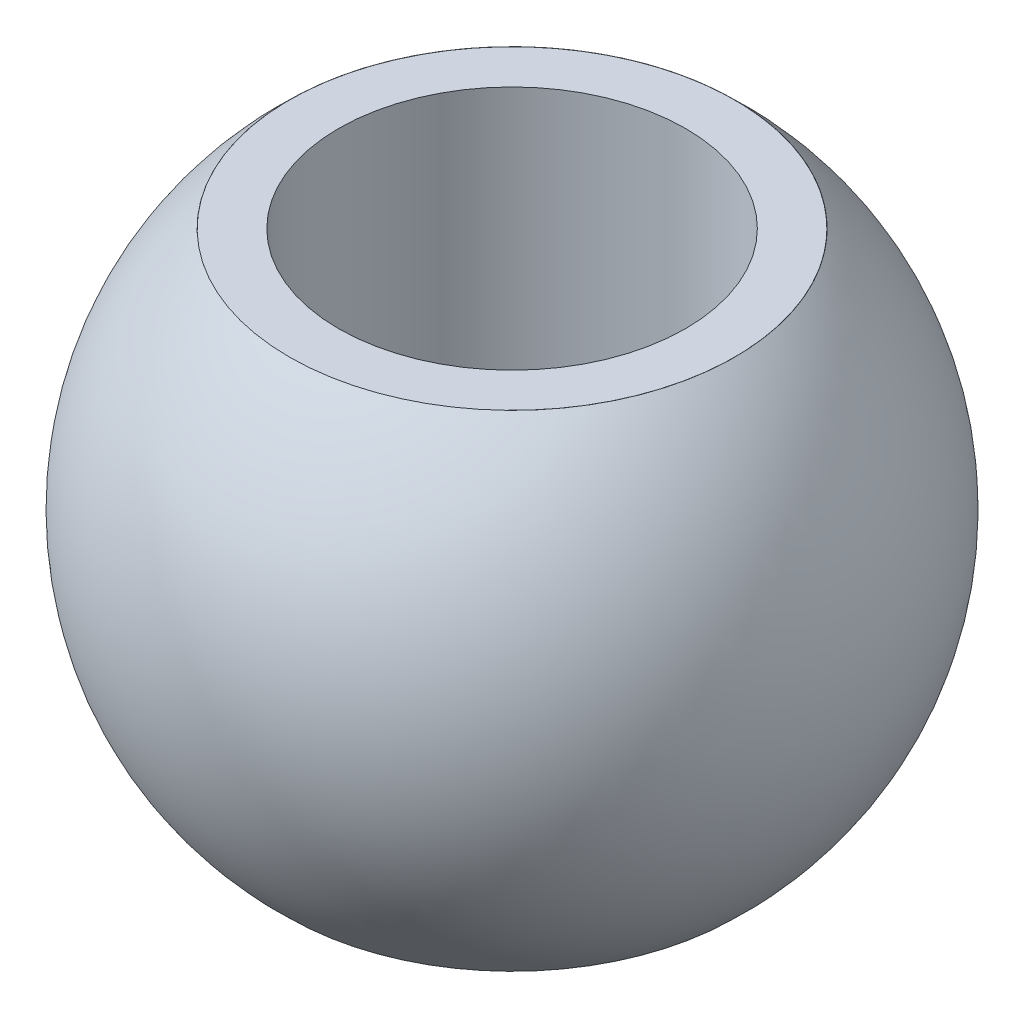
from build123d import *

# Parameters (mm, degrees)
CUT_EXTRUDE1_DEPTH      = 17.454482672
CUT_EXTRUDE1_DEPTH_BACK = 17.454482672
SKETCH1_3_R             = 5
CUT_EXTRUDE2_START      = 7
SKETCH1_4_R             = 6.42
SKETCH1_4_R_2           = 5
CUT_EXTRUDE2_DEPTH      = 10.454482672
CUT_EXTRUDE3_START      = -7
SKETCH1_5_R             = 6.42
SKETCH1_5_R_2           = 5
CUT_EXTRUDE3_DEPTH      = 10.454482672


with BuildPart() as part:
    # Sketch1 → Revolve1 (revolve)
    with BuildSketch(Plane(origin=(0, 0, 0), x_dir=(1, 0, 0), z_dir=(0, 1, 0))):
        with BuildLine():
            ThreePointArc((9.5, 0), (0, 9.5), (-9.5, 0))
            Line((-9.5, 0), (9.5, 0))
        make_face()
    revolve(axis=Axis((-9.5, 0, 0), (1, 0, 0)))

    # Sketch1_3 → Cut-Extrude1 (cut, two sides: drawn at the far end of the back side and taken through both)
    with BuildSketch(Plane(origin=(0, 0, 0), x_dir=(1, 0, 0), z_dir=(0, 1, 0)).offset(-CUT_EXTRUDE1_DEPTH_BACK)):
        Circle(SKETCH1_3_R)
    extrude(amount=CUT_EXTRUDE1_DEPTH + CUT_EXTRUDE1_DEPTH_BACK, mode=Mode.SUBTRACT)

    # Sketch1_4 → Cut-Extrude2 (cut, through all)
    with BuildSketch(Plane(origin=(0, 0, 0), x_dir=(1, 0, 0), z_dir=(0, 1, 0)).offset(CUT_EXTRUDE2_START)):
        Circle(SKETCH1_4_R)
        Circle(SKETCH1_4_R_2, mode=Mode.SUBTRACT)
    extrude(amount=CUT_EXTRUDE2_DEPTH, mode=Mode.SUBTRACT)

    # Sketch1_5 → Cut-Extrude3 (cut, through all)
    with BuildSketch(Plane(origin=(0, 0, 0), x_dir=(1, 0, 0), z_dir=(0, 1, 0)).offset(CUT_EXTRUDE3_START)):
        Circle(SKETCH1_5_R)
        Circle(SKETCH1_5_R_2, mode=Mode.SUBTRACT)
    extrude(amount=-CUT_EXTRUDE3_DEPTH, mode=Mode.SUBTRACT)


solid = part.part
